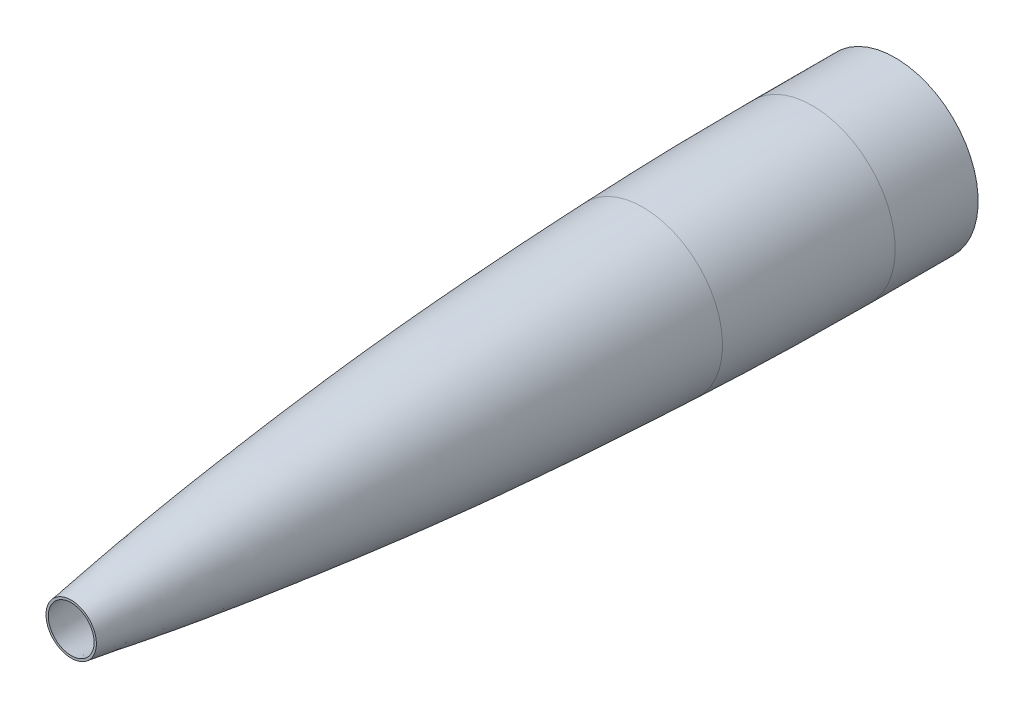
from build123d import *

# Parameters (mm, degrees)
SHELL1_T = -2.159


with BuildPart() as part:
    # Sketch1 → Revolve1 (revolve)
    with BuildSketch(Plane(origin=(0, 0, 0), x_dir=(1, 0, 0), z_dir=(0, 1, 0)), mode=Mode.PRIVATE) as revolve1_sk:
        with BuildLine():
            ThreePointArc((76.199999999, 547.325214574), (77.819198282, 602.449655946), (78.359, 657.595231051))
            Line((78.359, 657.595231051), (78.359, 788.90114))
            Line((78.359, 788.90114), (0, 788.90114))
            Line((0, 788.90114), (0, 64.584297407))
            Line((0, 64.584297407), (31.75, 64.584297407))
            Line((31.75, 64.584297407), (33.885466684, 64.266393269))
            add(Edge.make_bspline(
                [(33.885466684, 64.266393269), (42.348373346, 121.114521501), (50.811280009, 187.507732985), (59.274186672, 281.958770773), (67.737093334, 331.288364803), (76.199999999, 547.325214574)],
                knots=[0.252398739, 0.252398739, 0.252398739, 0.252398739, 0.252398739, 0.252398739, 0.966193801, 0.966193801, 0.966193801, 0.966193801, 0.966193801, 0.966193801], degree=5))
        make_face()
        with BuildLine():
            add(Edge.make_bspline(
                [(24.130000001, 1e-09), (26.081093337, 13.719418368), (28.032186674, 26.243143495), (29.983280011, 38.561458819), (31.934373347, 51.160257443), (33.885466684, 64.266393269)],
                knots=[0.0878358, 0.0878358, 0.0878358, 0.0878358, 0.0878358, 0.0878358, 0.252398739, 0.252398739, 0.252398739, 0.252398739, 0.252398739, 0.252398739], degree=5))
            Line((33.885466684, 64.266393269), (31.75, 64.584297407))
            Line((31.75, 64.584297407), (0, 64.584297407))
            Line((0, 64.584297407), (0, 0))
            Line((0, 0), (24.13, 0))
        make_face()
    revolve(revolve1_sk.sketch.rotate(Axis((0, 0, -788.90114), (0, 0, 1)), 180), axis=Axis((0, 0, -788.90114), (0, 0, 1)))

    # Shell1
    shell1_openings = [part.faces().sort_by_distance(p)[0] for p in [
        (0, 0, -788.90114),
        (0, 0, 0),
    ]]
    offset(amount=SHELL1_T, openings=shell1_openings, kind=Kind.INTERSECTION)

    # Sketch2 → Revolve2 (revolve)
    with BuildSketch(Plane(origin=(0, 0, 0), x_dir=(1, 0, 0), z_dir=(0, 1, 0)), mode=Mode.PRIVATE) as revolve2_sk:
        with BuildLine():
            ThreePointArc((76.199999999, 547.325214574), (77.819198282, 602.449655945), (78.359, 657.595231051))
            Line((78.359, 657.595231051), (78.359, 788.90114))
            Line((78.359, 788.90114), (79.375, 788.90114))
            Line((79.375, 788.90114), (79.375, 709.487003497))
            ThreePointArc((79.375, 709.487003497), (78.581173944, 628.390569525), (76.199999999, 547.325214574))
        make_face()
    revolve(revolve2_sk.sketch.rotate(Axis((0, 0, -788.90114), (0, 0, 1)), 180), axis=Axis((0, 0, -788.90114), (0, 0, 1)))


solid = part.part
